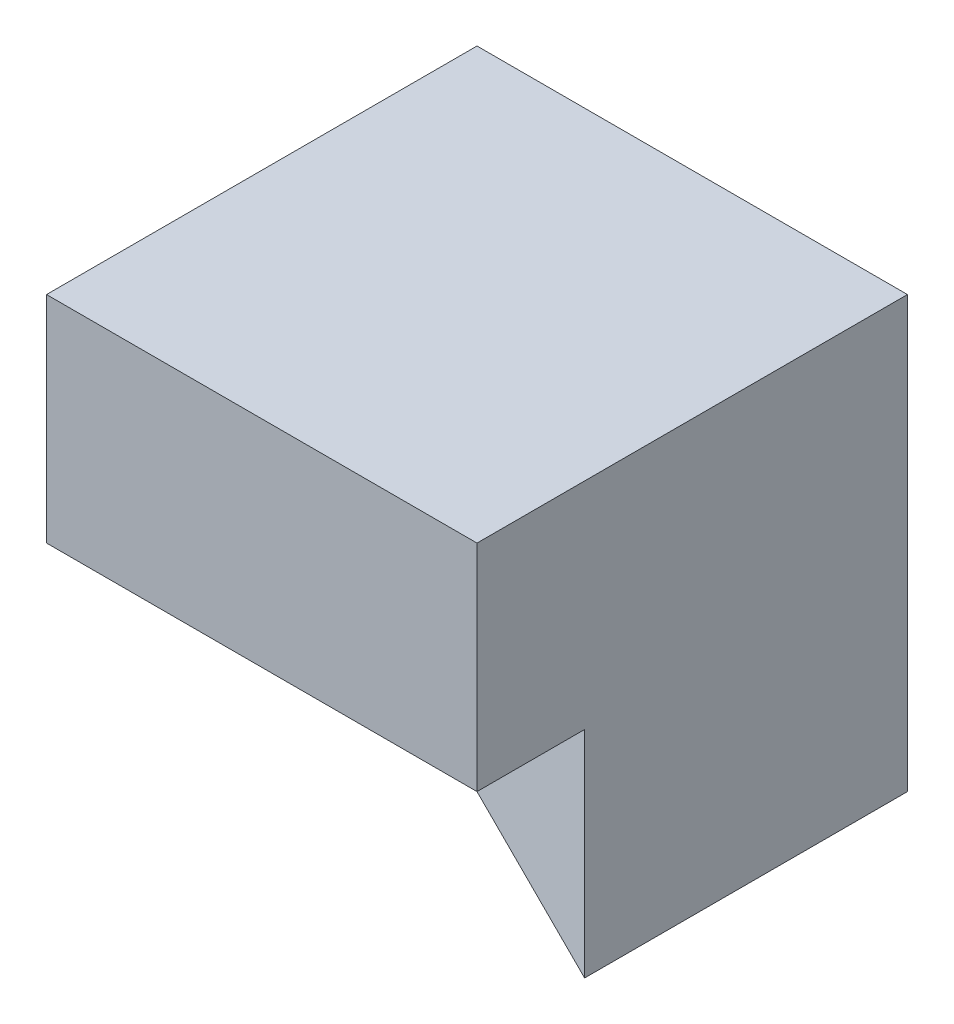
from build123d import *

# Parameters (mm, degrees)
SKETCH1_W           = 40
SKETCH1_H           = 40
BOSS_EXTRUDE1_DEPTH = 40
SKETCH2_W           = 10
SKETCH2_H           = 20
CUT_EXTRUDE1_DEPTH  = 40
SKETCH3_W           = 20
SKETCH3_H           = 20
CUT_EXTRUDE3_DEPTH  = 47
BOSS_EXTRUDE5_DEPTH = 20


with BuildPart() as part:
    # Sketch1 → Boss-Extrude1 (new body)
    with BuildSketch(Plane.XY):
        with Locations((20, 20)):
            Rectangle(SKETCH1_W, SKETCH1_H)
    extrude(amount=BOSS_EXTRUDE1_DEPTH)

    # Sketch2 → Cut-Extrude1 (cut)
    with BuildSketch(Plane.ZY):
        with Locations((35, 10)):
            Rectangle(SKETCH2_W, SKETCH2_H)
    extrude(amount=-CUT_EXTRUDE1_DEPTH, mode=Mode.SUBTRACT)

    # Sketch3 → Cut-Extrude3 (cut)
    with BuildSketch(Plane.ZY):
        with Locations((20, 10)):
            Rectangle(SKETCH3_W, SKETCH3_H)
    extrude(amount=-CUT_EXTRUDE3_DEPTH, mode=Mode.SUBTRACT)

    # Sketch10 → Boss-Extrude5 (add)
    with BuildSketch(Plane(origin=(0, 20, 0), x_dir=(1, 0, 0), z_dir=(0, 1, 0))):
        Polygon((40, -30), (40, -10), (0, -10), align=None)
    extrude(amount=-BOSS_EXTRUDE5_DEPTH)


solid = part.part
